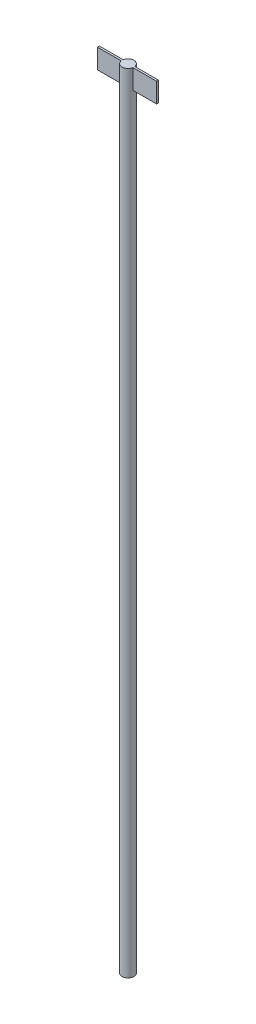
from build123d import *

# Parameters (mm, degrees)
SKETCH1_R           = 1.5
BOSS_EXTRUDE1_DEPTH = 100
SKETCH2_W           = 15
SKETCH2_H           = 0.5
BOSS_EXTRUDE2_DEPTH = 5


with BuildPart() as part:
    # Sketch1 → Boss-Extrude1 (new body, symmetric)
    with BuildSketch(Plane(origin=(0, 0, 0), x_dir=(1, 0, 0), z_dir=(0, 1, 0))):
        Circle(SKETCH1_R)
    extrude(amount=BOSS_EXTRUDE1_DEPTH, both=True)

    # Sketch2 → Boss-Extrude2 (add)
    with BuildSketch(Plane(origin=(0, 100, 0), x_dir=(1, 0, 0), z_dir=(0, 1, 0))):
        Rectangle(SKETCH2_W, SKETCH2_H)
    extrude(amount=-BOSS_EXTRUDE2_DEPTH)


solid = part.part
